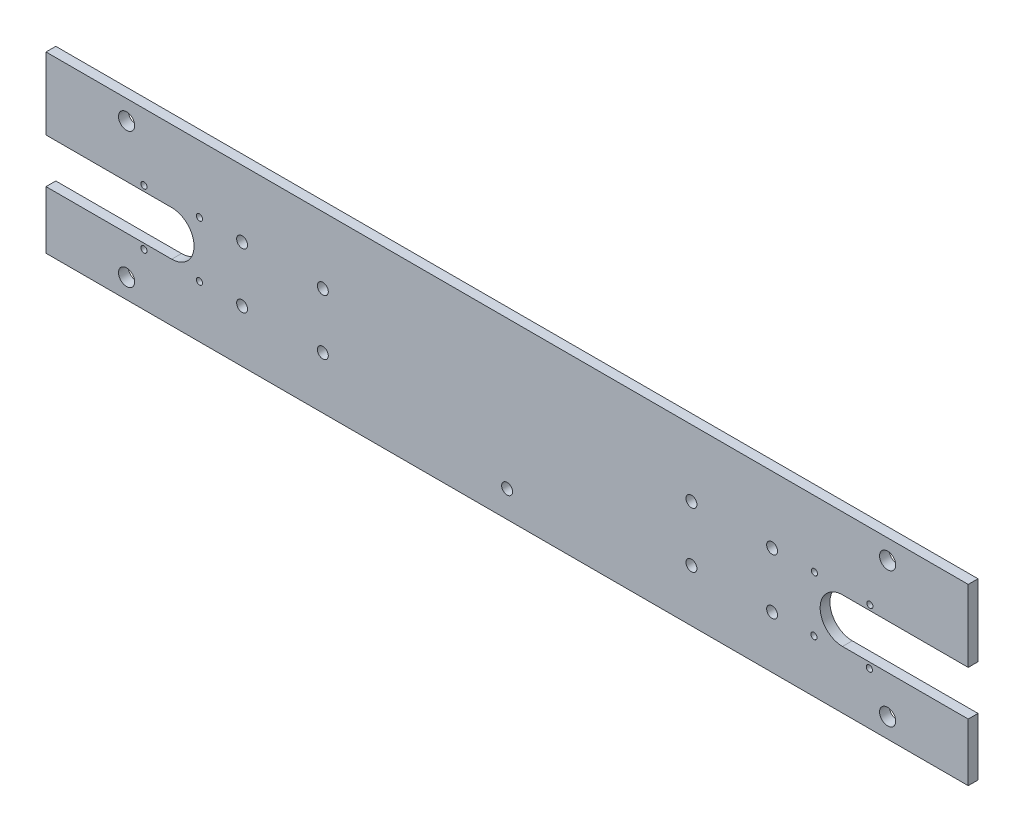
from build123d import *

# Parameters (mm, degrees)
SKETCH1_W           = 299.398126018
SKETCH1_H           = 56.59882
SKETCH1_R           = 2.625
BOSS_EXTRUDE1_DEPTH = 3.175
SKETCH2_R           = 1
CUT_EXTRUDE1_DEPTH  = 4.175
SKETCH3_R           = 1.778
CUT_EXTRUDE2_DEPTH  = 4.175
CUT_EXTRUDE3_DEPTH  = 4.175


with BuildPart() as part:
    # Sketch1 → Boss-Extrude1 (new body)
    with BuildSketch(Plane.XY):
        with Locations((162.727004442, 111.211757818)):
            Rectangle(SKETCH1_W, SKETCH1_H)
        with Locations((286.266607451, 133.161167818)):
            Circle(SKETCH1_R, mode=Mode.SUBTRACT)
        with Locations((286.266607451, 89.262347818)):
            Circle(SKETCH1_R, mode=Mode.SUBTRACT)
        with Locations((39.187401433, 133.161167818)):
            Circle(SKETCH1_R, mode=Mode.SUBTRACT)
        with Locations((39.187401433, 89.262347818)):
            Circle(SKETCH1_R, mode=Mode.SUBTRACT)
    extrude(amount=BOSS_EXTRUDE1_DEPTH)

    # Sketch2 → Cut-Extrude1 (cut, through all)
    with BuildSketch(Plane.XY.offset(3.175)):
        with Locations((280.504156768, 117.824340674)):
            Circle(SKETCH2_R)
        with Locations((280.335334394, 99.825132385)):
            Circle(SKETCH2_R)
        with Locations((262.504948479, 117.993163047)):
            Circle(SKETCH2_R)
        with Locations((262.336126106, 99.993954759)):
            Circle(SKETCH2_R)
        with Locations((62.845741433, 117.909047818)):
            Circle(SKETCH2_R)
        with Locations((62.845741433, 99.909047818)):
            Circle(SKETCH2_R)
        with Locations((44.845741433, 117.909047818)):
            Circle(SKETCH2_R)
        with Locations((44.845741433, 99.909047818)):
            Circle(SKETCH2_R)
    extrude(amount=-CUT_EXTRUDE1_DEPTH, mode=Mode.SUBTRACT)

    # Sketch3 → Cut-Extrude2 (cut, through all)
    with BuildSketch(Plane.XY.offset(3.175)):
        with Locations((76.695557497, 117.909047818)):
            Circle(SKETCH3_R)
        with Locations((76.695557497, 99.909047818)):
            Circle(SKETCH3_R)
        with Locations((102.895189625, 117.909047818)):
            Circle(SKETCH3_R)
        with Locations((102.895189625, 99.909047818)):
            Circle(SKETCH3_R)
        with Locations((248.758451386, 99.909047818)):
            Circle(SKETCH3_R)
        with Locations((222.558819258, 99.909047818)):
            Circle(SKETCH3_R)
        with Locations((222.558819258, 117.909047818)):
            Circle(SKETCH3_R)
        with Locations((248.758451386, 117.909047818)):
            Circle(SKETCH3_R)
        with Locations((162.727004442, 91.563754554)):
            Circle(SKETCH3_R)
    extrude(amount=-CUT_EXTRUDE2_DEPTH, mode=Mode.SUBTRACT)

    # Sketch5 → Cut-Extrude3 (cut, through all)
    with BuildSketch(Plane.XY.offset(3.175)):
        with BuildLine():
            Line((53.845741433, 116.163287818), (13.027941433, 116.163287818))
            Line((13.027941433, 116.163287818), (13.027941433, 101.654807818))
            Line((13.027941433, 101.654807818), (53.845741433, 101.654807818))
            ThreePointArc((53.845741433, 101.654807818), (61.099981433, 108.909047818), (53.845741433, 116.163287818))
        make_face()
        with BuildLine():
            Line((271.608267451, 101.654807818), (312.426067451, 101.654807818))
            Line((312.426067451, 101.654807818), (312.426067451, 116.163287818))
            Line((312.426067451, 116.163287818), (271.608267451, 116.163287818))
            ThreePointArc((271.608267451, 116.163287818), (264.354027451, 108.909047818), (271.608267451, 101.654807818))
        make_face()
    extrude(amount=-CUT_EXTRUDE3_DEPTH, mode=Mode.SUBTRACT)


solid = part.part
